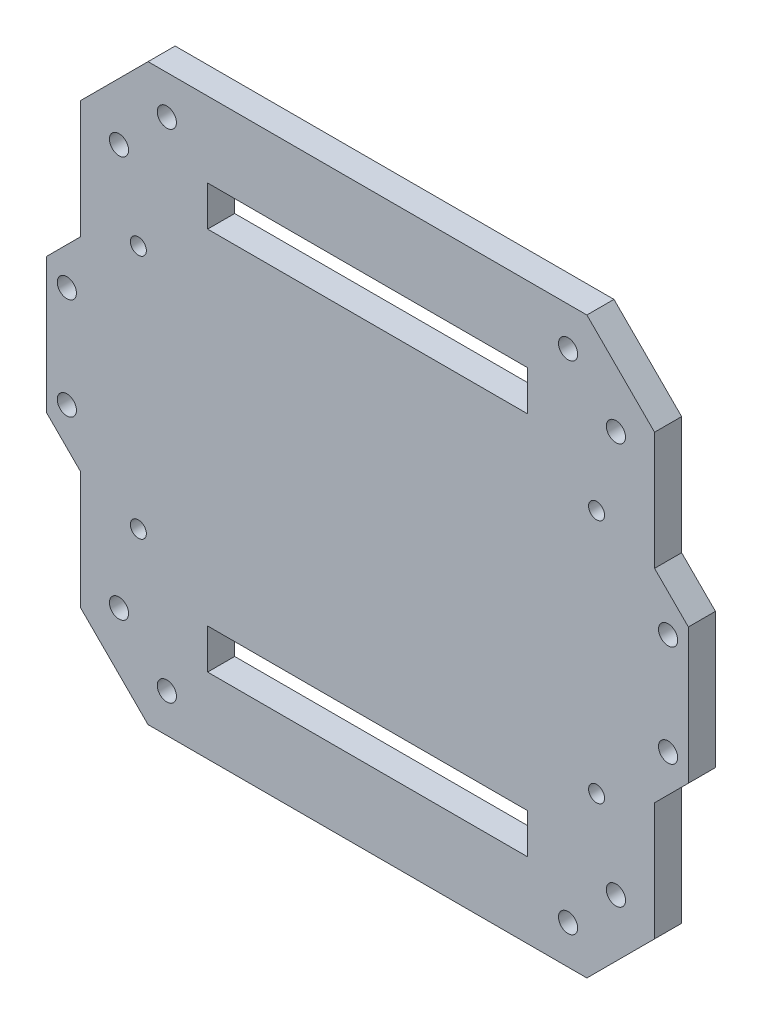
from build123d import *

# Parameters (mm, degrees)
SKETCH1_R           = 1.8
SKETCH1_R_2         = 1.5
SKETCH1_W           = 7.5
SKETCH1_H           = 60
BOSS_EXTRUDE1_DEPTH = 5.08


with BuildPart() as part:
    # Sketch1 → Boss-Extrude1 (new body)
    with BuildSketch(Plane(origin=(0, 0, 0), x_dir=(0, 1, 0), z_dir=(0, 0, 1))):
        Polygon((-41.181536726, 53.881536726), (-19.05, 53.881536726), (-12.7, 60.231536726), (12.7, 60.231536726), (19.05, 53.881536726), (41.181536726, 53.881536726), (53.881536726, 41.181536726), (53.881536726, -41.181536726), (41.181536726, -53.881536726), (19.05, -53.881536726), (12.7, -60.231536726), (-12.7, -60.231536726), (-19.05, -53.881536726), (-41.181536726, -53.881536726), (-53.881536726, -41.181536726), (-53.881536726, 41.181536726), align=None)
        with Locations((-46.633511114, -37.653254993)):
            Circle(SKETCH1_R, mode=Mode.SUBTRACT)
        with Locations((-37.653254993, -46.633511114)):
            Circle(SKETCH1_R, mode=Mode.SUBTRACT)
        with Locations((46.633511114, -37.653254993)):
            Circle(SKETCH1_R, mode=Mode.SUBTRACT)
        with Locations((37.653254993, -46.633511114)):
            Circle(SKETCH1_R, mode=Mode.SUBTRACT)
        with Locations((-46.633511114, 37.653254993)):
            Circle(SKETCH1_R, mode=Mode.SUBTRACT)
        with Locations((-37.653254993, 46.633511114)):
            Circle(SKETCH1_R, mode=Mode.SUBTRACT)
        with Locations((37.653254993, 46.633511114)):
            Circle(SKETCH1_R, mode=Mode.SUBTRACT)
        with Locations((46.633511114, 37.653254993)):
            Circle(SKETCH1_R, mode=Mode.SUBTRACT)
        with Locations((-23, 43)):
            Circle(SKETCH1_R_2, mode=Mode.SUBTRACT)
        with Locations((23, 43)):
            Circle(SKETCH1_R_2, mode=Mode.SUBTRACT)
        with Locations((-23, -43)):
            Circle(SKETCH1_R_2, mode=Mode.SUBTRACT)
        with Locations((23, -43)):
            Circle(SKETCH1_R_2, mode=Mode.SUBTRACT)
        with Locations((9.525, -56.421536726)):
            Circle(SKETCH1_R, mode=Mode.SUBTRACT)
        with Locations((-9.525, -56.421536726)):
            Circle(SKETCH1_R, mode=Mode.SUBTRACT)
        with Locations((-9.525, 56.421536726)):
            Circle(SKETCH1_R, mode=Mode.SUBTRACT)
        with Locations((9.525, 56.421536726)):
            Circle(SKETCH1_R, mode=Mode.SUBTRACT)
        with Locations((-36, 0)):
            Rectangle(SKETCH1_W, SKETCH1_H, mode=Mode.SUBTRACT)
        with Locations((36, 0)):
            Rectangle(SKETCH1_W, SKETCH1_H, mode=Mode.SUBTRACT)
    extrude(amount=BOSS_EXTRUDE1_DEPTH)


solid = part.part
